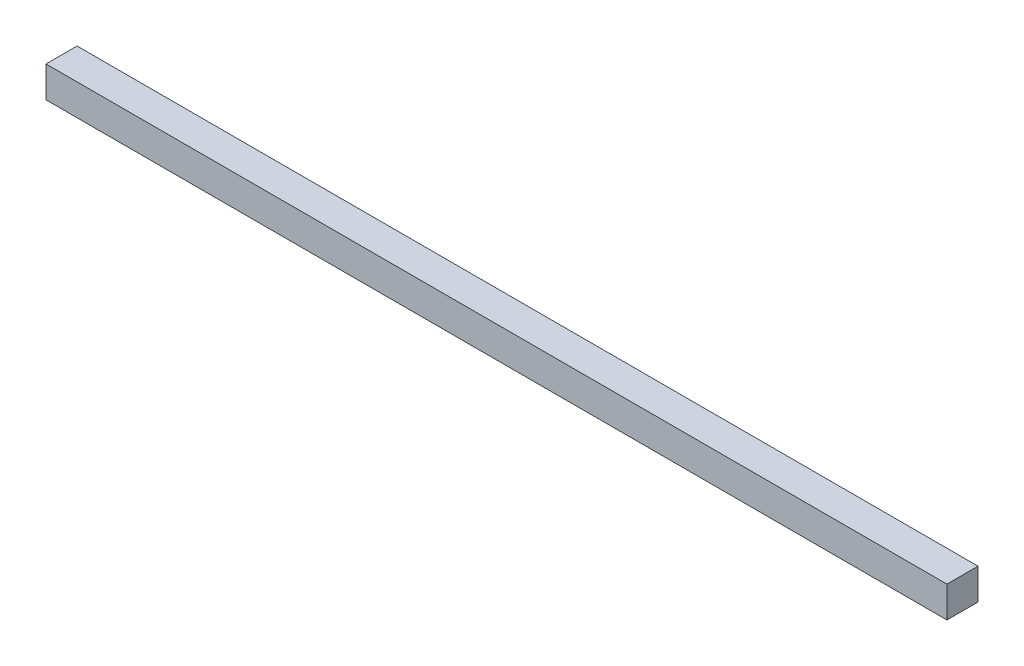
from build123d import *

# Parameters (mm, degrees)
SKETCH1_W           = 36.83
SKETCH1_H           = 1.27
BOSS_EXTRUDE1_DEPTH = 1.27


with BuildPart() as part:
    # Sketch1 → Boss-Extrude1 (new body)
    with BuildSketch(Plane.XY):
        with Locations((18.415, 0.635)):
            Rectangle(SKETCH1_W, SKETCH1_H)
    extrude(amount=BOSS_EXTRUDE1_DEPTH)


solid = part.part
